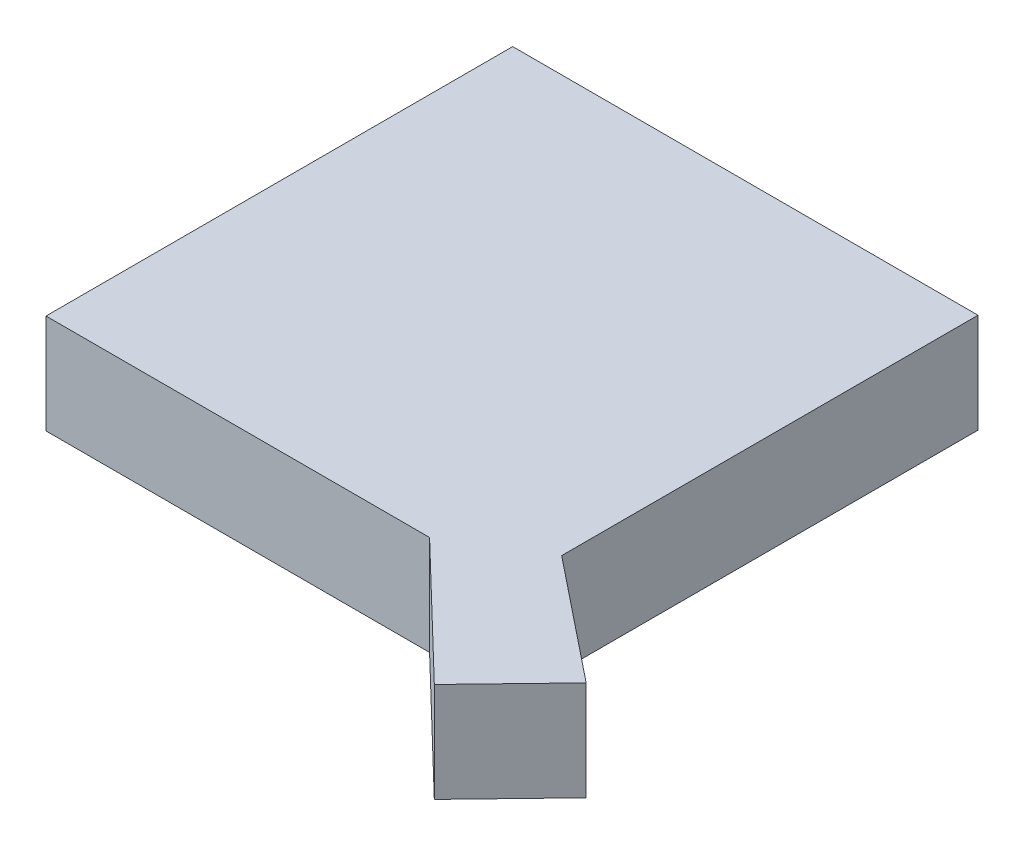
from build123d import *

# Parameters (mm, degrees)
BOSS_EXTRUDE1_DEPTH = 10


with BuildPart() as part:
    # Sketch1 → Boss-Extrude1 (new body)
    with BuildSketch(Plane(origin=(0, 0, 0), x_dir=(1, 0, 0), z_dir=(0, 1, 0))):
        Polygon((0, 0), (0, 46.881453643), (46.74477302, 46.881453643), (46.74477302, 5.057183046), (59.046029078, -4.7838218), (51.5617213, -12.552379779), (38.532608525, 0), align=None)
    extrude(amount=BOSS_EXTRUDE1_DEPTH)


solid = part.part
